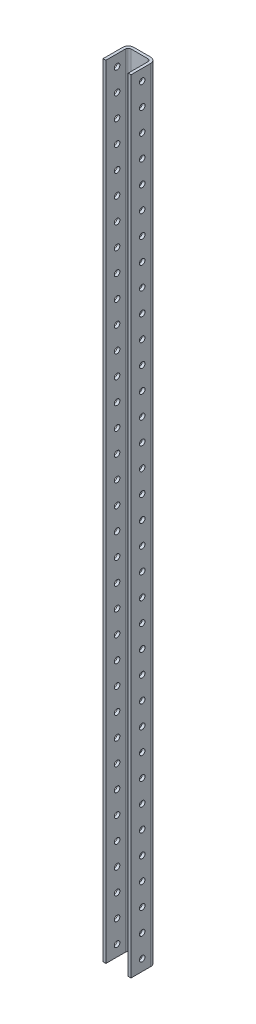
from build123d import *

# Parameters (mm, degrees)
EXTRUDE1_DEPTH = 444.5
SKETCH2_R      = 4.826
SKETCH2_R_2    = 1.5875
EXTRUDE2_DEPTH = 25
SKETCH3_R      = 3.175
EXTRUDE3_DEPTH = 35


with BuildPart() as part:
    # Sketch1 → Extrude1 (new body, symmetric)
    with BuildSketch(Plane(origin=(0, 0, 0), x_dir=(1, 0, 0), z_dir=(0, 1, 0))):
        with BuildLine():
            Line((-12.7, 0), (-12.7, 22.225))
            ThreePointArc((-12.7, 22.225), (-11.77006403, 24.47006403), (-9.525, 25.4))
            Line((-9.525, 25.4), (9.525, 25.4))
            ThreePointArc((9.525, 25.4), (11.77006403, 24.47006403), (12.7, 22.225))
            Line((12.7, 22.225), (12.7, 0))
            Line((12.7, 0), (15.875, 0))
            Line((15.875, 0), (15.875, 22.225))
            ThreePointArc((15.875, 22.225), (14.015128061, 26.715128061), (9.525, 28.575))
            Line((9.525, 28.575), (-9.525, 28.575))
            ThreePointArc((-9.525, 28.575), (-14.015128061, 26.715128061), (-15.875, 22.225))
            Line((-15.875, 22.225), (-15.875, 0))
            Line((-15.875, 0), (-12.7, 0))
        make_face()
    extrude(amount=EXTRUDE1_DEPTH, both=True)

    # Sketch2 → Extrude2 (cut)
    with BuildSketch(Plane(origin=(0, 0, -28.575), x_dir=(-1, 0, 0), z_dir=(0, 0, -1))):
        with Locations((1.905, 361.95)):
            Circle(SKETCH2_R)
        with Locations((1.905, 336.55)):
            Circle(SKETCH2_R)
        with Locations((1.905, 107.95)):
            Circle(SKETCH2_R)
        with Locations((1.905, 82.55)):
            Circle(SKETCH2_R)
        with Locations((-1.905, 0)):
            Circle(SKETCH2_R)
        with Locations((1.905, -361.95)):
            Circle(SKETCH2_R)
        with Locations((1.905, -336.55)):
            Circle(SKETCH2_R)
        with Locations((1.905, -82.55)):
            Circle(SKETCH2_R)
        with Locations((1.905, -107.95)):
            Circle(SKETCH2_R)
        with Locations((0, -241.3)):
            Circle(SKETCH2_R_2)
    extrude(amount=-EXTRUDE2_DEPTH, mode=Mode.SUBTRACT)

    # Sketch3 → Extrude3 (cut)
    with BuildSketch(Plane(origin=(15.875, 0, 0), x_dir=(0, 0, -1), z_dir=(1, 0, 0))):
        with Locations((12.7, 431.8)):
            Circle(SKETCH3_R)
        with Locations((12.7, 406.4)):
            Circle(SKETCH3_R)
        with Locations((12.7, 381)):
            Circle(SKETCH3_R)
        with Locations((12.7, 355.6)):
            Circle(SKETCH3_R)
        with Locations((12.7, 330.2)):
            Circle(SKETCH3_R)
        with Locations((12.7, 304.8)):
            Circle(SKETCH3_R)
        with Locations((12.7, 279.4)):
            Circle(SKETCH3_R)
        with Locations((12.7, 254)):
            Circle(SKETCH3_R)
        with Locations((12.7, 228.6)):
            Circle(SKETCH3_R)
        with Locations((12.7, 203.2)):
            Circle(SKETCH3_R)
        with Locations((12.7, 177.8)):
            Circle(SKETCH3_R)
        with Locations((12.7, 152.4)):
            Circle(SKETCH3_R)
        with Locations((12.7, 127)):
            Circle(SKETCH3_R)
        with Locations((12.7, 101.6)):
            Circle(SKETCH3_R)
        with Locations((12.7, 76.2)):
            Circle(SKETCH3_R)
        with Locations((12.7, 50.8)):
            Circle(SKETCH3_R)
        with Locations((12.7, 25.4)):
            Circle(SKETCH3_R)
        with Locations((12.7, 0)):
            Circle(SKETCH3_R)
        with Locations((12.7, -25.4)):
            Circle(SKETCH3_R)
        with Locations((12.7, -50.8)):
            Circle(SKETCH3_R)
        with Locations((12.7, -76.2)):
            Circle(SKETCH3_R)
        with Locations((12.7, -101.6)):
            Circle(SKETCH3_R)
        with Locations((12.7, -127)):
            Circle(SKETCH3_R)
        with Locations((12.7, -152.4)):
            Circle(SKETCH3_R)
        with Locations((12.7, -177.8)):
            Circle(SKETCH3_R)
        with Locations((12.7, -203.2)):
            Circle(SKETCH3_R)
        with Locations((12.7, -228.6)):
            Circle(SKETCH3_R)
        with Locations((12.7, -254)):
            Circle(SKETCH3_R)
        with Locations((12.7, -279.4)):
            Circle(SKETCH3_R)
        with Locations((12.7, -304.8)):
            Circle(SKETCH3_R)
        with Locations((12.7, -330.2)):
            Circle(SKETCH3_R)
        with Locations((12.7, -355.6)):
            Circle(SKETCH3_R)
        with Locations((12.7, -381)):
            Circle(SKETCH3_R)
        with Locations((12.7, -406.4)):
            Circle(SKETCH3_R)
        with Locations((12.7, -431.8)):
            Circle(SKETCH3_R)
    extrude(amount=-EXTRUDE3_DEPTH, mode=Mode.SUBTRACT)


solid = part.part
